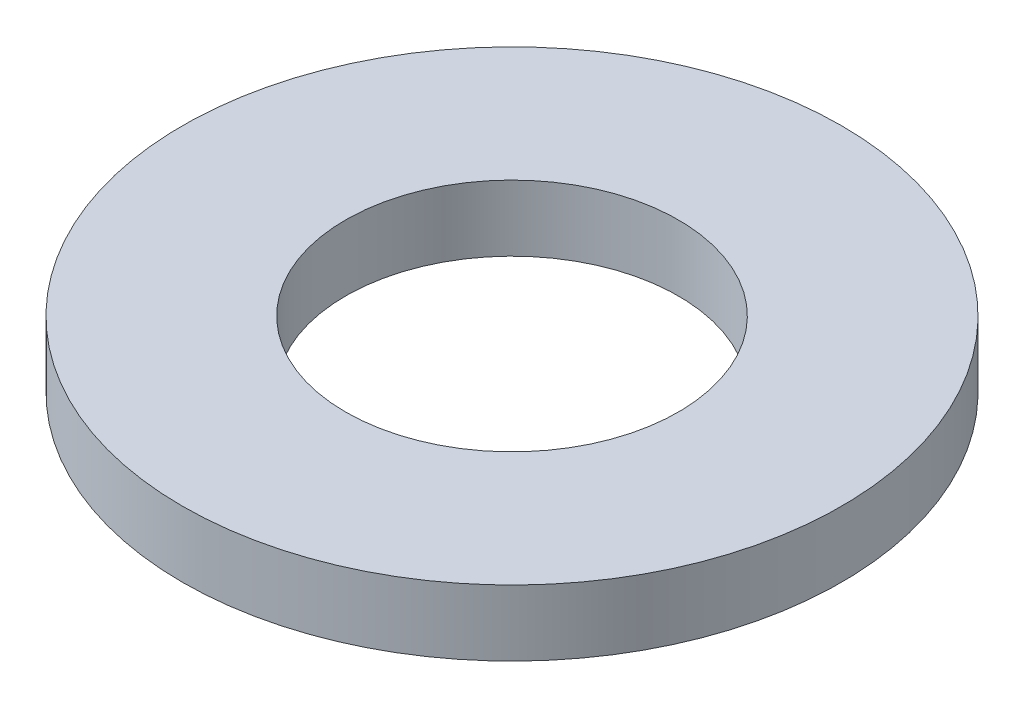
from build123d import *

# Parameters (mm, degrees)
SKETCH1_R           = 5
SKETCH1_R_2         = 2.525
BOSS_EXTRUDE1_DEPTH = 1


with BuildPart() as part:
    # Sketch1 → Boss-Extrude1 (new body)
    with BuildSketch(Plane(origin=(0, 0, 0), x_dir=(1, 0, 0), z_dir=(0, 1, 0))):
        Circle(SKETCH1_R)
        Circle(SKETCH1_R_2, mode=Mode.SUBTRACT)
    extrude(amount=BOSS_EXTRUDE1_DEPTH)


solid = part.part
